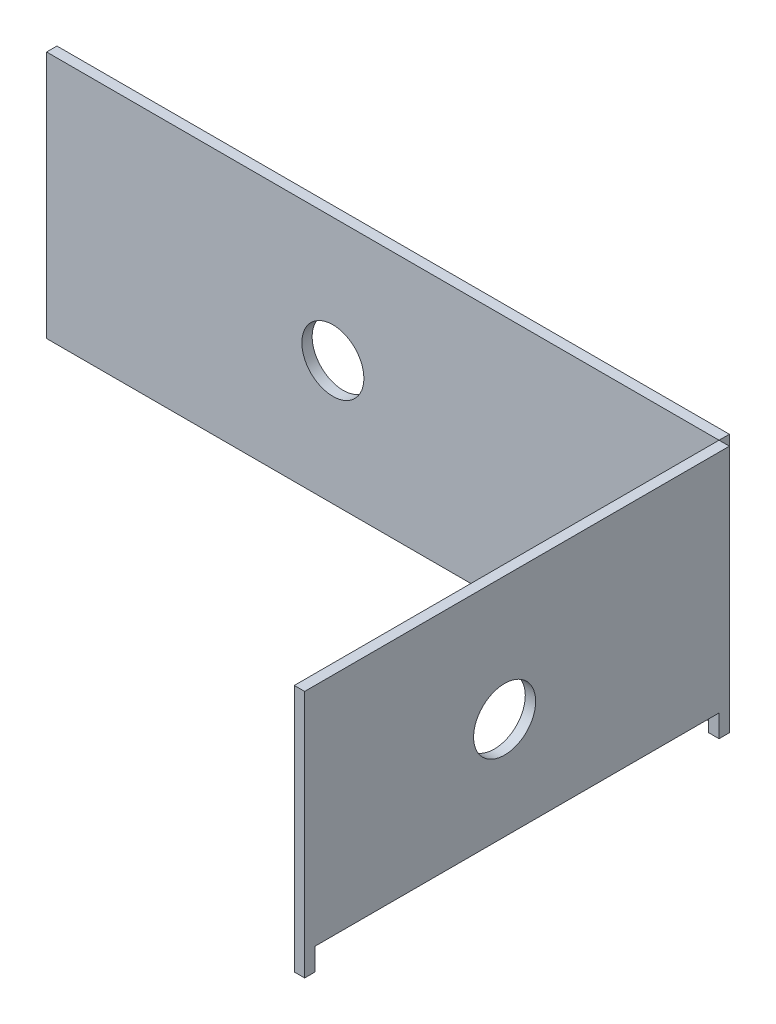
from build123d import *

# Parameters (mm, degrees)
SKETCH2_R           = 9.525
BOSS_EXTRUDE3_DEPTH = 3.175
SKETCH9_R           = 9.525
BOSS_EXTRUDE5_DEPTH = 3.175


with BuildPart() as part:
    # Sketch2 → Boss-Extrude3 (new body)
    with BuildSketch(Plane.XY):
        Polygon((-33.735047644, 0), (160.016152356, 0), (166.366152356, 0), (166.366152356, -76.2), (-40.085047644, -76.2), (-40.085047644, 0), align=None)
        with Locations((47.798952356, -38.1)):
            Circle(SKETCH2_R, mode=Mode.SUBTRACT)
    extrude(amount=BOSS_EXTRUDE3_DEPTH)


with BuildPart() as body_2:
    # Sketch9 → Boss-Extrude5 (new body)
    with BuildSketch(Plane(origin=(166.366152356, 0, 0), x_dir=(0, 0, -1), z_dir=(1, 0, 0))):
        Polygon((-3.175, 0), (-133.5786, 0), (-133.5786, -76.2), (-130.4036, -76.2), (-130.4036, -69.342), (-6.35, -69.342), (-6.35, -76.2), (-3.175, -76.2), align=None)
        with Locations((-72.1868, -38.1)):
            Circle(SKETCH9_R, mode=Mode.SUBTRACT)
    extrude(amount=BOSS_EXTRUDE5_DEPTH)


solid = Compound([part.part, body_2.part])
